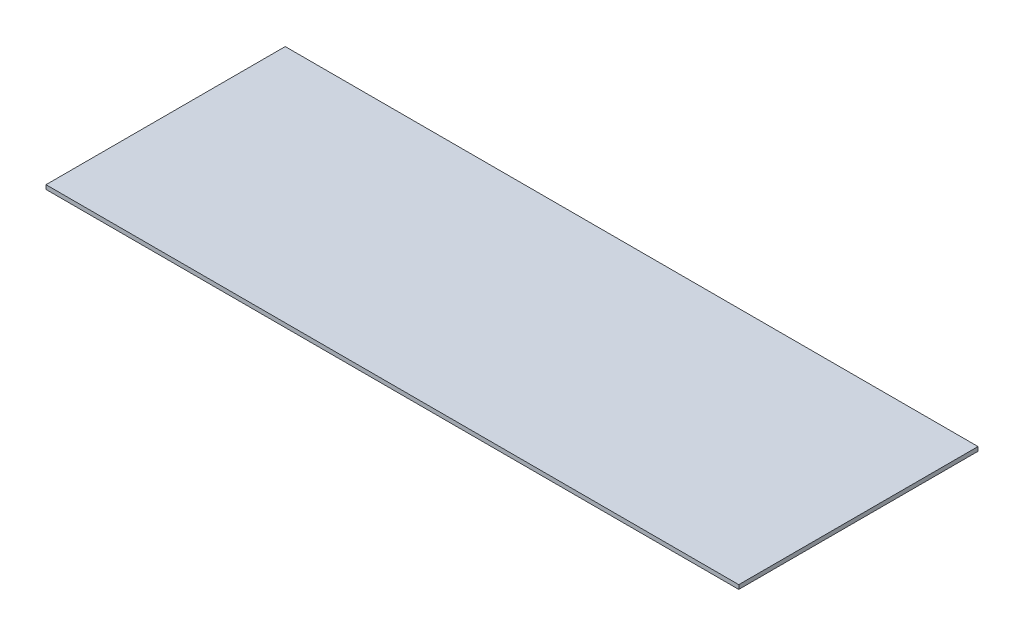
from build123d import *

# Parameters (mm, degrees)
SKETCH_1_W      = 300
SKETCH_1_H      = 103.6
EXTRUDE_1_DEPTH = 1.8


with BuildPart() as part:
    # 草图1 → 凸台-拉伸1 (new body)
    with BuildSketch(Plane(origin=(0, 0, 0), x_dir=(1, 0, 0), z_dir=(0, 1, 0))):
        with Locations((150, 51.8)):
            Rectangle(SKETCH_1_W, SKETCH_1_H)
    extrude(amount=EXTRUDE_1_DEPTH)


solid = part.part
